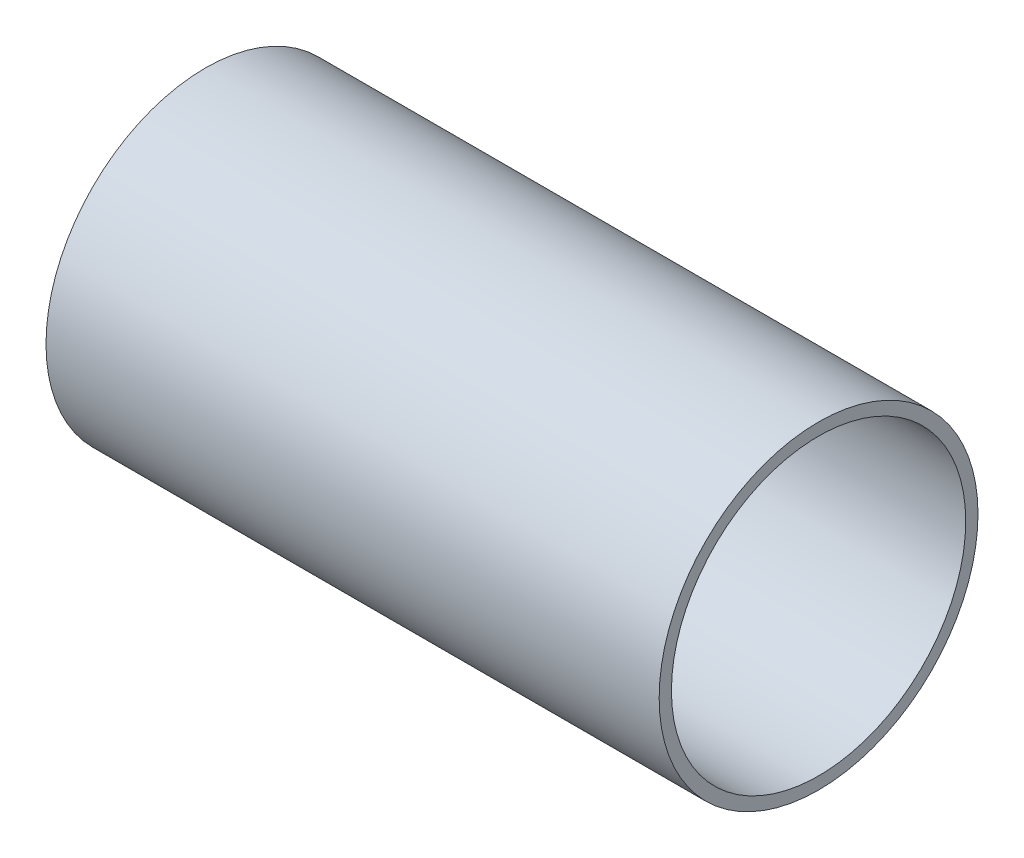
from build123d import *

# Parameters (mm, degrees)
SKETCH2_R           = 49.53
BOSS_EXTRUDE1_DEPTH = 203.2
SKETCH3_R           = 12.411567775
BOSS_EXTRUDE2_DEPTH = 50.8
SKETCH4_R           = 49.53
CUT_EXTRUDE1_DEPTH  = 381
SHELL1_T            = -3.81


with BuildPart() as part:
    # Sketch1 → Revolve2 (revolve)
    with BuildSketch(Plane(origin=(0, 0, 0), x_dir=(1, 0, 0), z_dir=(0, 1, 0))):
        with BuildLine():
            Line((355.600000053, 50.799999973), (355.600000053, 1.269999973))
            Line((355.600000053, 1.269999973), (50.800000047, 1.269999973))
            Line((50.800000047, 1.269999973), (50.800000047, 13.68156774))
            add(Edge.make_bspline(
                [(50.800000047, 13.68156774), (51.224607869, 13.786541703), (52.079748124, 13.99736018), (53.901316113, 14.445024847), (55.90428978, 14.933081433), (57.918204029, 15.420277853), (59.969167456, 15.913068852), (62.005618607, 16.398707152), (64.04585603, 16.881716673), (66.619566178, 17.486536085), (69.727395203, 18.209576077), (73.370678613, 19.04644661), (77.55044141, 19.991710093), (82.779136229, 21.155661521), (97.433989811, 24.348822924), (119.485629173, 28.81699746), (168.00075752, 37.516041455), (219.035004801, 44.081341124), (262.822405655, 47.820230422), (299.206459448, 49.570692635), (308.841173655, 49.947366018), (315.265578413, 50.162354186), (319.548981494, 50.29122703), (323.832782669, 50.405645805), (328.116966628, 50.505609209), (332.401425999, 50.591116104), (336.139078075, 50.653092889), (339.329601827, 50.697064227), (341.973247658, 50.727612371), (344.069774299, 50.748376802), (346.163273231, 50.76568058), (348.272494467, 50.77952366), (350.344714481, 50.789906003), (352.405704949, 50.79682758), (354.282013928, 50.799423175), (355.162608625, 50.799999974), (355.600000053, 50.799999973)],
                knots=[0.08282658, 0.08282658, 0.08282658, 0.08282658, 0.08282658, 0.088510594, 0.094194608, 0.099878623, 0.105562637, 0.111246651, 0.116930666, 0.12261468, 0.128298694, 0.139917182, 0.15153567, 0.163154157, 0.174772645, 0.198009616, 0.314194483, 0.407142375, 0.709223026, 0.755696971, 0.790552431, 0.802170918, 0.813789405, 0.825407891, 0.837026378, 0.848644864, 0.860263351, 0.871881838, 0.877565852, 0.883249866, 0.88893388, 0.894617894, 0.900301908, 0.905985922, 0.911669936, 0.91735395, 0.91735395, 0.91735395, 0.91735395, 0.91735395], degree=4))
        make_face()
    revolve(axis=Axis((355.600000053, 0, -1.269999973), (-1, 0, 0)))

    # Sketch2 → Boss-Extrude1 (add)
    with BuildSketch(Plane(origin=(355.600000053, 0, 0), x_dir=(0, 0, -1), z_dir=(1, 0, 0))):
        with Locations((1.269999973, 0)):
            Circle(SKETCH2_R)
    extrude(amount=BOSS_EXTRUDE1_DEPTH)

    # Sketch3 → Boss-Extrude2 (add)
    with BuildSketch(Plane.ZY.offset(-50.800000063)):
        with Locations((-1.269999973, 0)):
            Circle(SKETCH3_R)
    extrude(amount=BOSS_EXTRUDE2_DEPTH)

    # Sketch4 → Cut-Extrude1 (cut)
    with BuildSketch(Plane(origin=(368.300000053, 0, 0), x_dir=(0, 0, -1), z_dir=(1, 0, 0))):
        with Locations((1.269999973, 0)):
            Circle(SKETCH4_R)
    extrude(amount=-CUT_EXTRUDE1_DEPTH, mode=Mode.SUBTRACT)

    # Shell1
    shell1_openings = [part.faces().sort_by_distance(p)[0] for p in [
        (558.800000053, 0, -1.269999973),
        (368.300000053, 0, -1.269999973),
    ]]
    offset(amount=SHELL1_T, openings=shell1_openings, kind=Kind.INTERSECTION)


solid = part.part
